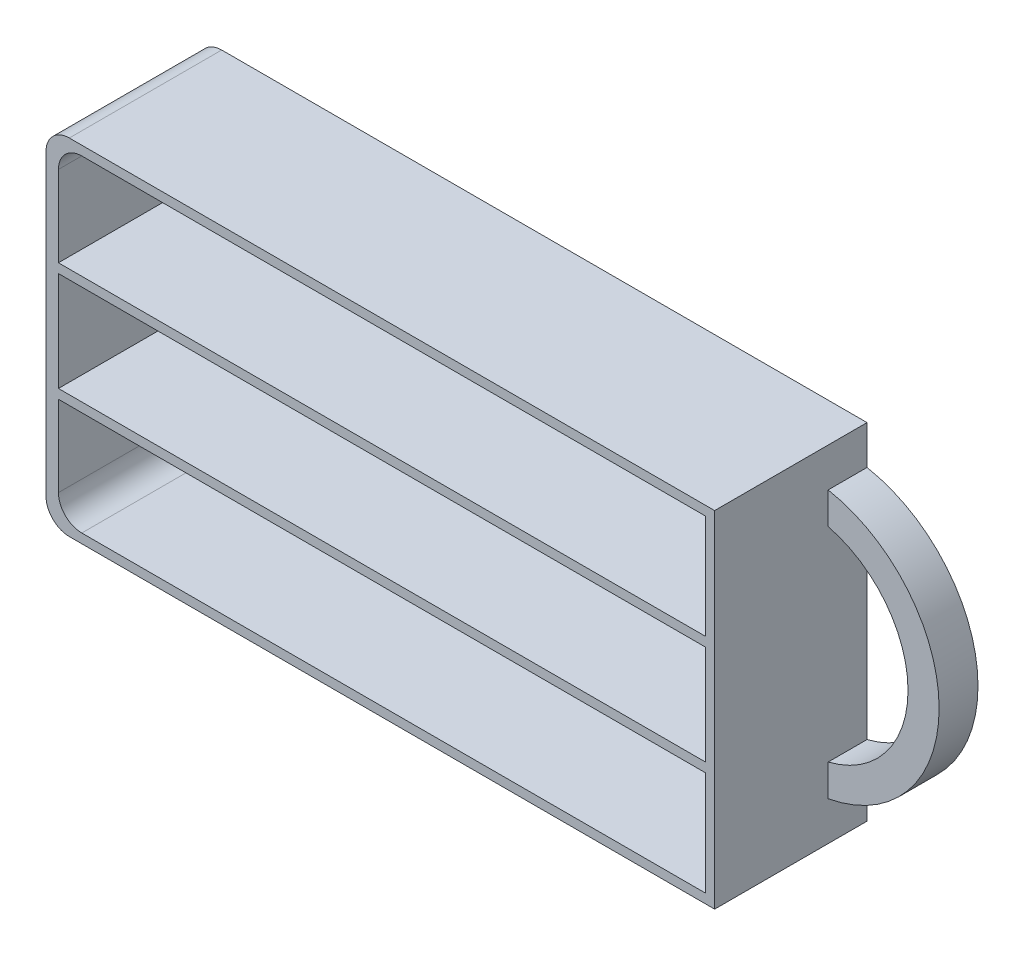
from build123d import *

# Parameters (mm, degrees)
SKETCH_1_W          = 86
SKETCH_1_H          = 44.4
EXTRUDE_1_DEPTH     = 19.6
EXTRUDE_2_DEPTH     = 5
SKETCH_3_W          = 83.2
SKETCH_3_H          = 13.4
SKETCH_3_H_2        = 12.8
CUT_EXTRUDE_1_DEPTH = 18.4
FILLET_1_R          = 3


with BuildPart() as part:
    # Эскиз1 → Бобышка-Вытянуть1 (new body)
    with BuildSketch(Plane.XY):
        Rectangle(SKETCH_1_W, SKETCH_1_H)
    extrude(amount=EXTRUDE_1_DEPTH)

    # Эскиз2 → Бобышка-Вытянуть2 (add)
    with BuildSketch(Plane.XY):
        with BuildLine():
            Line((43, 17.2), (43, 13.108775687))
            ThreePointArc((43, 13.108775687), (53.273546839, 0), (43, -13.108775687))
            Line((43, -13.108775687), (43, -17.2))
            ThreePointArc((43, -17.2), (57.273546839, 0), (43, 17.2))
        make_face()
    extrude(amount=EXTRUDE_2_DEPTH)

    # Эскиз3 → Вырез-Вытянуть1 (cut)
    with BuildSketch(Plane.XY.offset(19.6)):
        with Locations((0.2, 14.3)):
            Rectangle(SKETCH_3_W, SKETCH_3_H)
        with Locations((0.2, 0)):
            Rectangle(SKETCH_3_W, SKETCH_3_H_2)
        with Locations((0.2, -14.3)):
            Rectangle(SKETCH_3_W, SKETCH_3_H)
    extrude(amount=-CUT_EXTRUDE_1_DEPTH, mode=Mode.SUBTRACT)

    # Скругление1
    fillet_1_edges = [part.edges().sort_by_distance(p)[0] for p in [
        (-41.4, 21, 10.4),
        (-41.4, -21, 10.4),
        (-43, -22.2, 9.8),
        (-43, 22.2, 9.8),
    ]]
    fillet(fillet_1_edges, radius=FILLET_1_R)


solid = part.part
